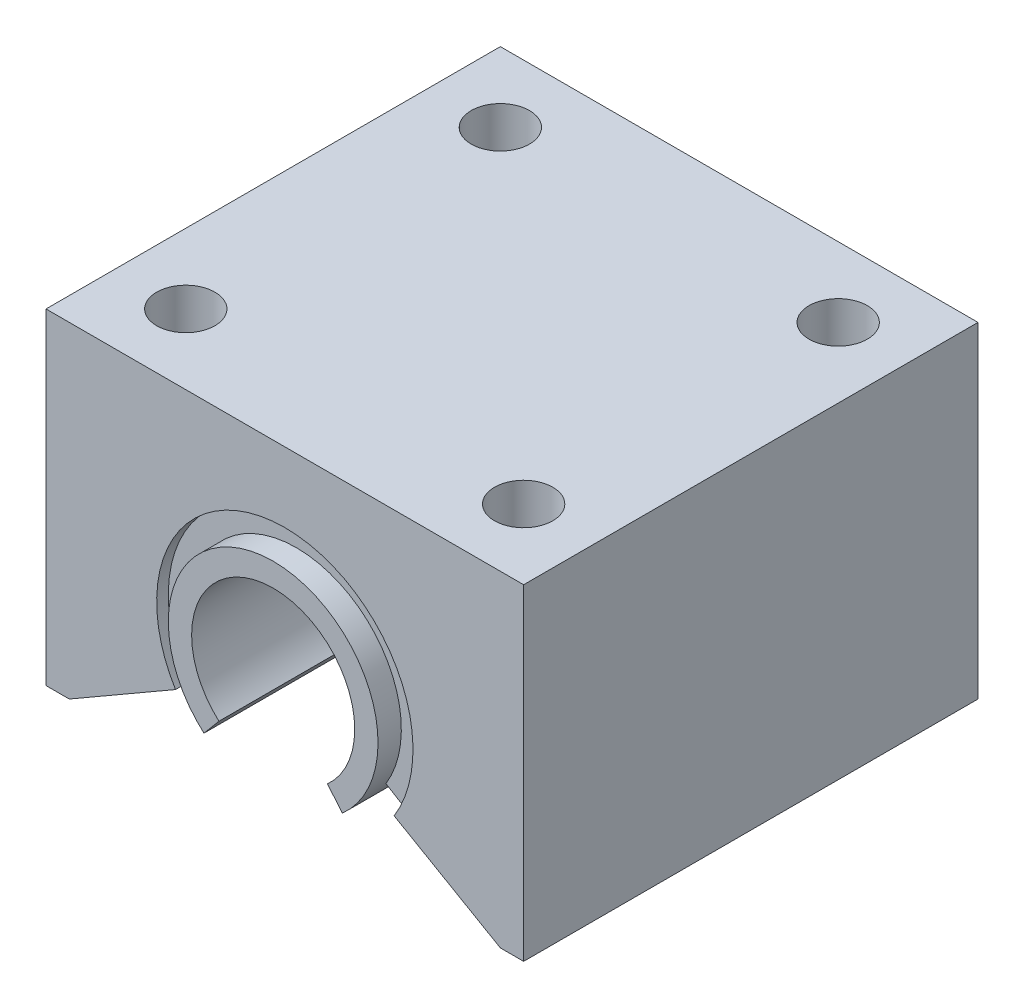
from build123d import *

# Parameters (mm, degrees)
BOSS_EXTRUDE1_DEPTH                  = 39
BOSS_EXTRUDE3_START                  = 1
BOSS_EXTRUDE3_DEPTH                  = 37
BOSS_EXTRUDE4_START                  = -1
BOSS_EXTRUDE4_DEPTH                  = 41
SKETCH4_R                            = 2.5
CUT_EXTRUDE1_DEPTH                   = 10
TAP_DRILL_FOR_M5X0_8_TAP1_AT_2_COUNT = 2
TAP_DRILL_FOR_M5X0_8_TAP1_AT_2_PITCH = 27
TAP_DRILL_FOR_M5X0_8_TAP1_AT_3_COUNT = 2
TAP_DRILL_FOR_M5X0_8_TAP1_AT_3_PITCH = 39.623223611
TAP_DRILL_FOR_M5X0_8_TAP1_AT_4_COUNT = 2
TAP_DRILL_FOR_M5X0_8_TAP1_AT_4_PITCH = 28.999998701


with BuildPart() as part:
    # Sketch1 → Boss-Extrude1 (new body)
    with BuildSketch(Plane.XY):
        with BuildLine():
            Line((-20.5, 14), (20.5, 14))
            Line((20.5, 14), (20.5, -14))
            Line((20.5, -14), (18.5, -14))
            Line((18.5, -14), (9.385134519, -8.737529961))
            ThreePointArc((9.385134519, -8.737529961), (0, 8), (-9.385134519, -8.737529961))
            Line((-9.385134519, -8.737529961), (-18.5, -14))
            Line((-18.5, -14), (-20.5, -14))
            Line((-20.5, -14), (-20.5, 14))
        make_face()
    extrude(amount=BOSS_EXTRUDE1_DEPTH)



with BuildPart() as body_2:
    # Sketch2 → Boss-Extrude3 (new body)
    with BuildSketch(Plane.XY.offset(BOSS_EXTRUDE3_START)):
        with BuildLine():
            Line((-9.385134519, -8.737529961), (-7.678746425, -7.694342695))
            ThreePointArc((-7.678746425, -7.694342695), (0, 6), (7.678746425, -7.694342695))
            Line((7.678746425, -7.694342695), (9.385134519, -8.737529961))
            ThreePointArc((9.385134519, -8.737529961), (0, 8), (-9.385134519, -8.737529961))
        make_face()
    extrude(amount=BOSS_EXTRUDE3_DEPTH)


with BuildPart() as part_1:
    add(part.part)

    add(body_2.part)  # Boss-Extrude4 merges body 2
    # Sketch3 → Boss-Extrude4 (add)
    with BuildSketch(Plane.XY.offset(BOSS_EXTRUDE4_START)):
        with BuildLine():
            Line((-5.9419479, -9.759678628), (-4.655936286, -8.227069666))
            ThreePointArc((-4.655936286, -8.227069666), (0, 4), (4.655936286, -8.227069666))
            Line((4.655936286, -8.227069666), (5.9419479, -9.759678628))
            ThreePointArc((5.9419479, -9.759678628), (0, 6), (-5.9419479, -9.759678628))
        make_face()
    extrude(amount=BOSS_EXTRUDE4_DEPTH)

    # Sketch4 → Cut-Extrude1 (cut)
    with BuildSketch(Plane(origin=(0, 14, 0), x_dir=(1, 0, 0), z_dir=(0, 1, 0))):
        with Locations(Location((-14.5, -6, 0), (0, 0, 270))):
            Circle(SKETCH4_R)
        with Locations(Location((14.499998701, -6, 0), (0, 0, 270))):
            Circle(SKETCH4_R)
        with Locations(Location((14.5, -33, 0), (0, 0, 270))):
            Circle(SKETCH4_R)
        with Locations(Location((-14.499998701, -33, 0), (0, 0, 270))):
            Circle(SKETCH4_R)
    extrude(amount=-CUT_EXTRUDE1_DEPTH, mode=Mode.SUBTRACT)

    # Sketch8 → Tap Drill for M5x0.8 Tap1 (revolve, cut)
    with BuildSketch(Plane(origin=(-14.499998701, 4, 33), x_dir=(0, 0, 1), z_dir=(1, 0, 0))):
        Polygon((0, 0), (0, 1.3118073), (2.1, 0.05), (2.1, 0.025), (2.125, 0), align=None)
    tap_drill_for_m5x0_8_tap1 = revolve(axis=Axis((-14.499998701, 10.35, 33), (0, -1, 0)), mode=Mode.SUBTRACT)

    # Tap Drill for M5x0.8 Tap1 at 2: Tap Drill for M5x0.8 Tap1 ×2
    with Locations(*[(0, 0, -i * TAP_DRILL_FOR_M5X0_8_TAP1_AT_2_PITCH) for i in range(1, TAP_DRILL_FOR_M5X0_8_TAP1_AT_2_COUNT)]):
        add(tap_drill_for_m5x0_8_tap1, mode=Mode.SUBTRACT)

    # Tap Drill for M5x0.8 Tap1 at 3: Tap Drill for M5x0.8 Tap1 ×2
    with Locations(*[Vector(0.7318939439938763, 0, -0.6814185606109426) * (i * TAP_DRILL_FOR_M5X0_8_TAP1_AT_3_PITCH) for i in range(1, TAP_DRILL_FOR_M5X0_8_TAP1_AT_3_COUNT)]):
        add(tap_drill_for_m5x0_8_tap1, mode=Mode.SUBTRACT)

    # Tap Drill for M5x0.8 Tap1 at 4: Tap Drill for M5x0.8 Tap1 ×2
    with Locations(*[(i * TAP_DRILL_FOR_M5X0_8_TAP1_AT_4_PITCH, 0, 0) for i in range(1, TAP_DRILL_FOR_M5X0_8_TAP1_AT_4_COUNT)]):
        add(tap_drill_for_m5x0_8_tap1, mode=Mode.SUBTRACT)


solid = part_1.part
